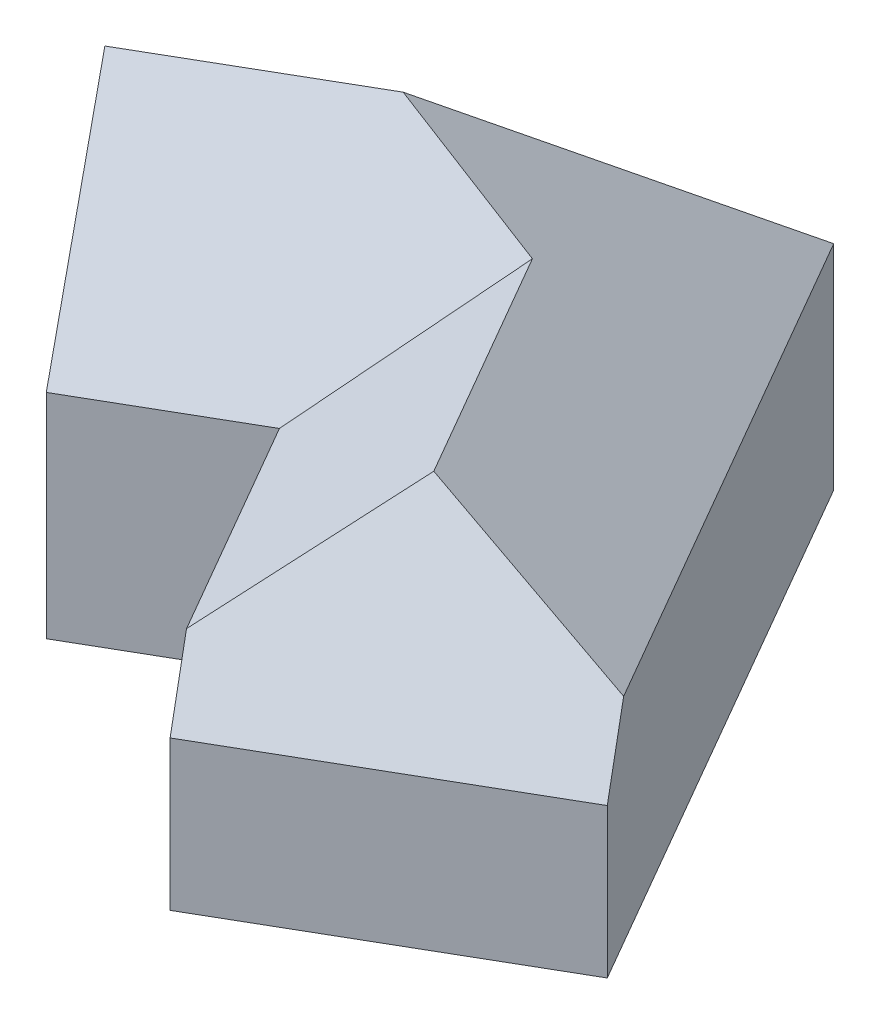
from build123d import *

# Parameters (mm, degrees)
EXTRUDE1_DEPTH     = 50
EXTRUDE2_DEPTH     = 115
EXTRUDE3_DEPTH     = 105
CUT_EXTRUDE1_DEPTH = 155
CUT_EXTRUDE2_DEPTH = 75


with BuildPart() as part:
    # Sketch1 → Extrude1 (new body)
    with BuildSketch(Plane(origin=(0, 0, 0), x_dir=(1, 0, 0), z_dir=(0, 1, 0))):
        Polygon((0, 0), (72.5, -125.573683549), (7.548094716, -163.073683549), (-27.451905284, -102.451905284), (-62.092921435, -122.451905284), (-99.592921435, -57.5), align=None)
    extrude(amount=EXTRUDE1_DEPTH)

    # Sketch2 → Extrude2 (add)
    with BuildSketch(Plane(origin=(-99.592921435, 0, 57.5), x_dir=(0.5, 0, 0.866025404), z_dir=(-0.866025404, 0, 0.5))):
        Polygon((75, 50), (0, 50), (37.5, 94.690759722), align=None)
    extrude(amount=-EXTRUDE2_DEPTH)

    # Sketch3 → Extrude3 (add)
    with BuildSketch(Plane(origin=(72.5, 0, 125.573683549), x_dir=(0.866025404, 0, -0.5), z_dir=(0.5, 0, 0.866025404))):
        Polygon((0, 50), (-75, 50), (-37.5, 76.257782683), align=None)
    extrude(amount=-EXTRUDE3_DEPTH)

    # Sketch4 → Cut-Extrude1 (cut)
    with BuildSketch(Plane(origin=(72.5, 0, 125.573683549), x_dir=(0.866025404, 0, -0.5), z_dir=(0.5, 0, 0.866025404))):
        Polygon((0, 50), (0, 113.526991311), (-90.725946016, 113.526991311), align=None)
    extrude(amount=-CUT_EXTRUDE1_DEPTH, mode=Mode.SUBTRACT)

    # Sketch5 → Cut-Extrude2 (cut)
    with BuildSketch(Plane(origin=(0, 0, 0), x_dir=(-0.5, 0, -0.866025404), z_dir=(0.866025404, 0, -0.5))):
        Polygon((-145, 35), (-97.861503451, 102.320749887), (-145, 102.320749887), align=None)
    extrude(amount=-CUT_EXTRUDE2_DEPTH, mode=Mode.SUBTRACT)


solid = part.part
